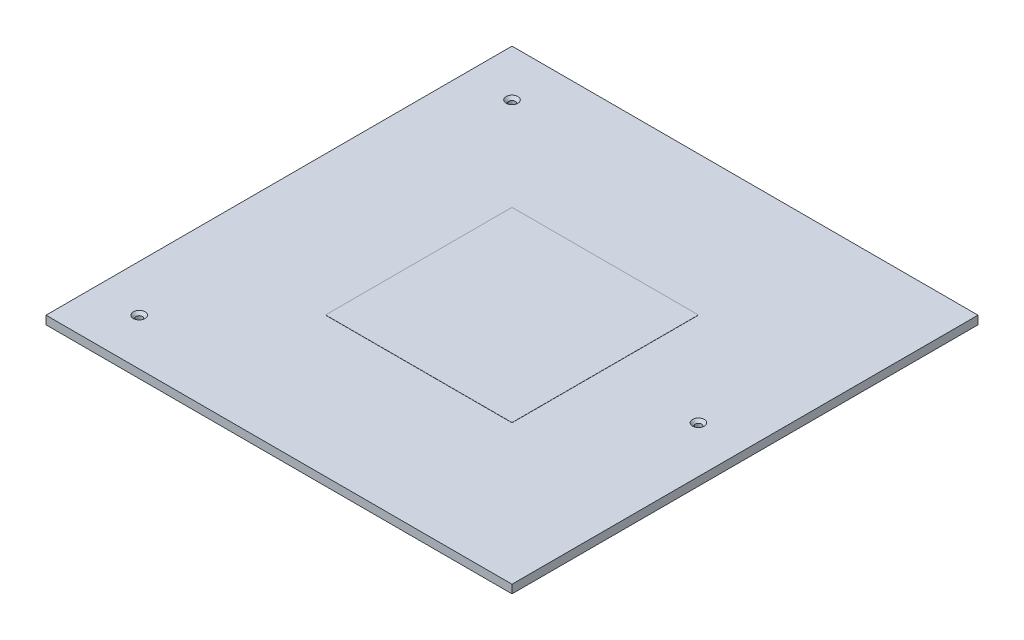
from build123d import *

# Parameters (mm, degrees)
SKETCH1_W                                       = 250
SKETCH1_H                                       = 250
BOSS_EXTRUDE2_DEPTH                             = 4.5
CSK_FOR_M3_FLAT_HEAD_MACHINE_SCREW1_D           = 3.4
CSK_FOR_M3_FLAT_HEAD_MACHINE_SCREW1_CSINK_D     = 6.3
CSK_FOR_M3_FLAT_HEAD_MACHINE_SCREW1_CSINK_ANGLE = 90
SKETCH5_W                                       = 100
SKETCH5_H                                       = 100
BOSS_EXTRUDE3_DEPTH                             = 0.1


with BuildPart() as part:
    # Sketch1 → Boss-Extrude2 (new body)
    with BuildSketch(Plane(origin=(0, 0, 0), x_dir=(1, 0, 0), z_dir=(0, 1, 0))):
        with Locations((125, 125)):
            Rectangle(SKETCH1_W, SKETCH1_H)
    extrude(amount=BOSS_EXTRUDE2_DEPTH)

    # CSK for M3 Flat Head Machine Screw1 (through all)
    with Locations(Plane(origin=(0, 4.5, 0), x_dir=(1, 0, 0), z_dir=(0, 1, 0))):
        with Locations((25, 25), (25, 225), (225, 125)):
            CounterSinkHole(CSK_FOR_M3_FLAT_HEAD_MACHINE_SCREW1_D / 2, CSK_FOR_M3_FLAT_HEAD_MACHINE_SCREW1_CSINK_D / 2, counter_sink_angle=CSK_FOR_M3_FLAT_HEAD_MACHINE_SCREW1_CSINK_ANGLE)

    # Sketch5 → Boss-Extrude3 (add)
    with BuildSketch(Plane(origin=(0, 4.5, 0), x_dir=(1, 0, 0), z_dir=(0, 1, 0))):
        with Locations((125, 125)):
            Rectangle(SKETCH5_W, SKETCH5_H)
    extrude(amount=BOSS_EXTRUDE3_DEPTH)


solid = part.part
